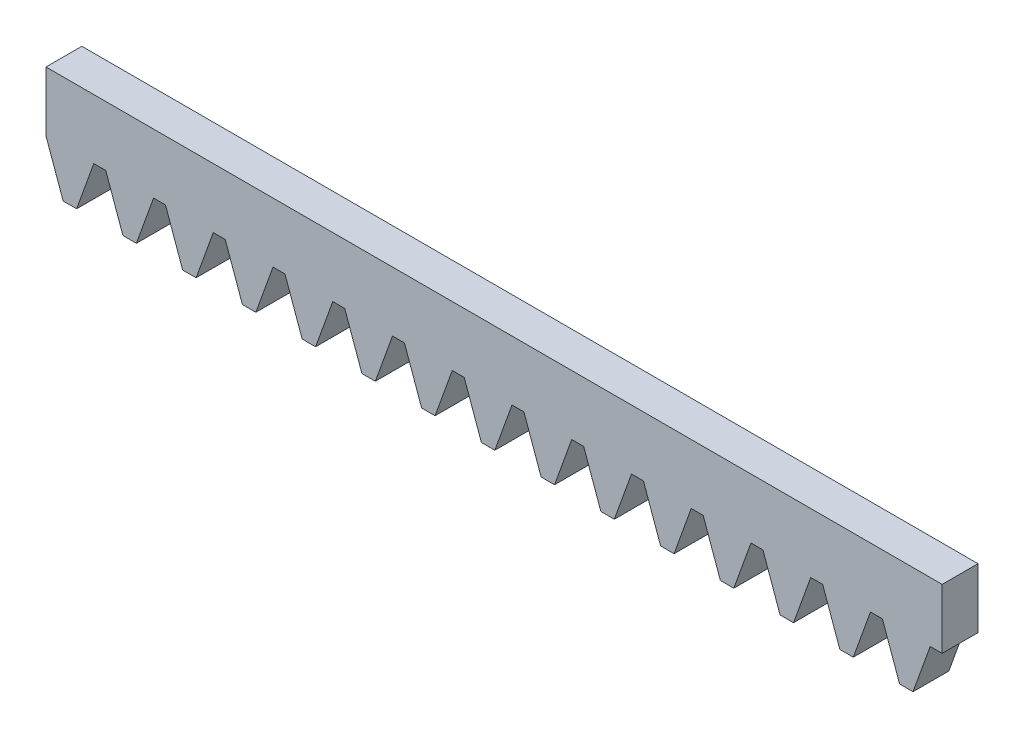
from build123d import *

# Parameters (mm, degrees)
BOSS_EXTRUDE1_DEPTH = 6
BOSS_EXTRUDE2_DEPTH = 6
LPATTERN1_COUNT     = 15
LPATTERN1_PITCH     = 10


with BuildPart() as part:
    # Sketch1 → Boss-Extrude1 (new body)
    with BuildSketch(Plane.XY):
        Polygon((-75, 5), (-75, -5), (-72, -5), (-70, -5), (-67, -5), (-62, -5), (-60, -5), (-52, -5), (-50, -5), (-42, -5), (-40, -5), (-32, -5), (-30, -5), (-22, -5), (-20, -5), (-12, -5), (-10, -5), (-2, -5), (0, -5), (8, -5), (10, -5), (18, -5), (20, -5), (28, -5), (30, -5), (38, -5), (40, -5), (48, -5), (50, -5), (58, -5), (60, -5), (68, -5), (70, -5), (75, -5), (75, 5), align=None)
    extrude(amount=BOSS_EXTRUDE1_DEPTH)

    # Sketch2 → Boss-Extrude2 (add)
    with BuildSketch(Plane.XY.offset(6)):
        Polygon((-75, -5), (-72.125, -13), (-69.875, -13), (-67, -5), align=None)
    boss_extrude2 = extrude(amount=-BOSS_EXTRUDE2_DEPTH)

    # LPattern1: Boss-Extrude2 ×15
    with Locations(*[(i * LPATTERN1_PITCH, 0, 0) for i in range(1, LPATTERN1_COUNT)]):
        add(boss_extrude2)


solid = part.part
